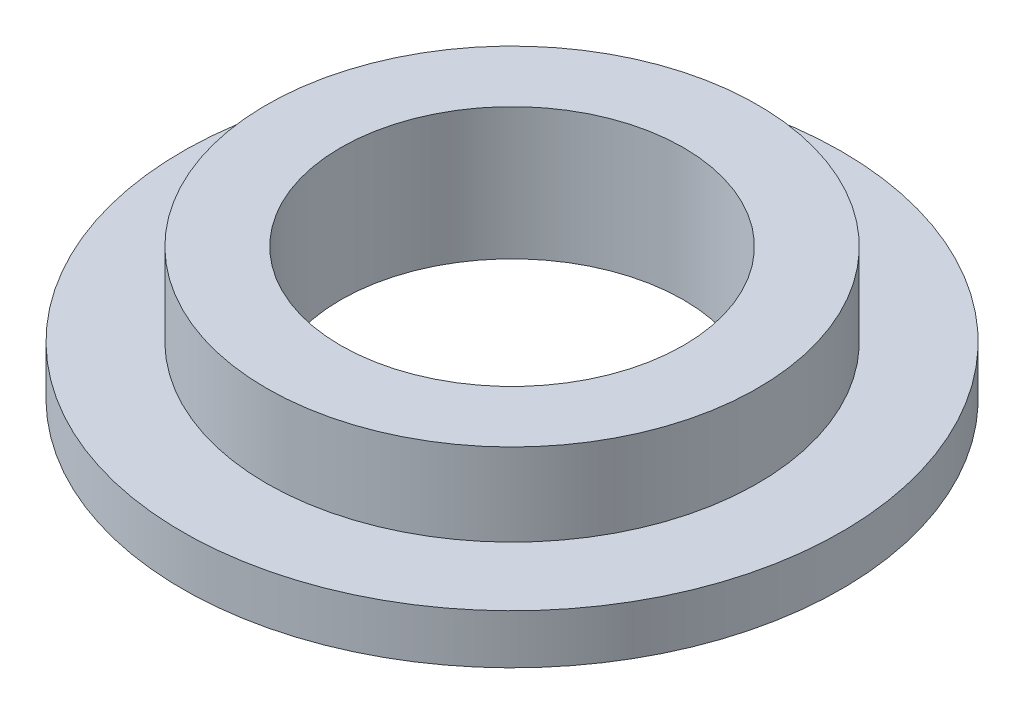
from build123d import *

# Parameters (mm, degrees)
SKETCH_1_R      = 14.9
SKETCH_1_R_2    = 10.4
EXTRUDE_1_DEPTH = 5
SKETCH_2_R      = 20
SKETCH_2_R_2    = 10.4
EXTRUDE_2_DEPTH = 3


with BuildPart() as part:
    # 草图1 → 凸台-拉伸1 (new body)
    with BuildSketch(Plane(origin=(0, 0, 0), x_dir=(1, 0, 0), z_dir=(0, 1, 0))):
        Circle(SKETCH_1_R)
        Circle(SKETCH_1_R_2, mode=Mode.SUBTRACT)
    extrude(amount=EXTRUDE_1_DEPTH)

    # 草图2 → 凸台-拉伸2 (add)
    with BuildSketch(Plane.XZ):
        Circle(SKETCH_2_R)
        Circle(SKETCH_2_R_2, mode=Mode.SUBTRACT)
    extrude(amount=EXTRUDE_2_DEPTH)


solid = part.part
